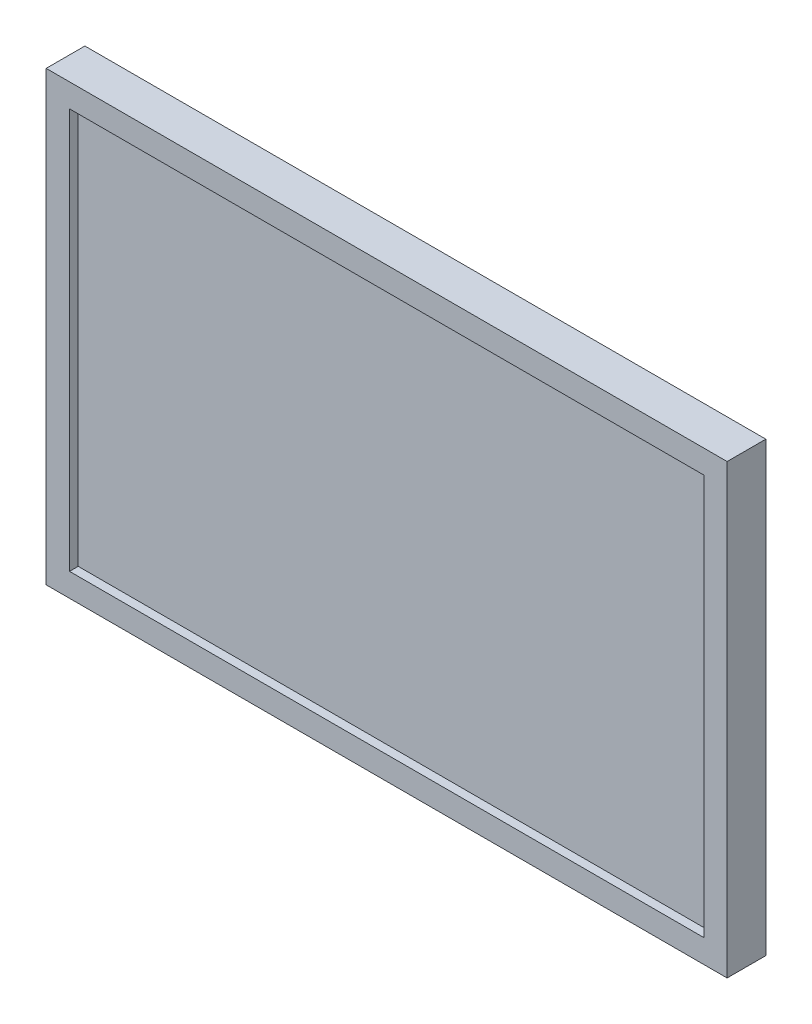
from build123d import *

# Parameters (mm, degrees)
SKETCH1_W           = 510
SKETCH1_H           = 335
BOSS_EXTRUDE1_DEPTH = 29
SKETCH2_W           = 475
SKETCH2_H           = 300
CUT_EXTRUDE1_DEPTH  = 6.5
SKETCH3_W           = 122
SKETCH3_H           = 122
BOSS_EXTRUDE2_DEPTH = 56
SKETCH4_R           = 2
CUT_EXTRUDE2_DEPTH  = 10
BOSS_EXTRUDE3_START = -56
SKETCH5_W           = 250
SKETCH5_H           = 154
SKETCH5_W_2         = 122
SKETCH5_H_2         = 122
BOSS_EXTRUDE3_DEPTH = 63
BOSS_EXTRUDE4_REACH = 360.798
BOSS_EXTRUDE5_REACH = 379.454
CUT_EXTRUDE3_DEPTH  = 63


with BuildPart() as part:
    # Sketch1 → Boss-Extrude1 (new body)
    with BuildSketch(Plane.XY):
        Rectangle(SKETCH1_W, SKETCH1_H)
    extrude(amount=-BOSS_EXTRUDE1_DEPTH)

    # Sketch2 → Cut-Extrude1 (cut)
    with BuildSketch(Plane.XY):
        Rectangle(SKETCH2_W, SKETCH2_H)
    extrude(amount=-CUT_EXTRUDE1_DEPTH, mode=Mode.SUBTRACT)

    # Sketch3 → Boss-Extrude2 (add)
    with BuildSketch(Plane(origin=(0, 0, -29), x_dir=(-1, 0, 0), z_dir=(0, 0, -1))):
        with Locations((0, 0.5)):
            Rectangle(SKETCH3_W, SKETCH3_H)
    extrude(amount=BOSS_EXTRUDE2_DEPTH)

    # Sketch4 → Cut-Extrude2 (cut)
    with BuildSketch(Plane(origin=(0, 0, -85), x_dir=(-1, 0, 0), z_dir=(0, 0, -1))):
        with Locations((-50, 50)):
            Circle(SKETCH4_R)
        with Locations((50, 50)):
            Circle(SKETCH4_R)
        with Locations((50, -50)):
            Circle(SKETCH4_R)
        with Locations((-50, -50)):
            Circle(SKETCH4_R)
    extrude(amount=-CUT_EXTRUDE2_DEPTH, mode=Mode.SUBTRACT)

    # Sketch5 → Boss-Extrude3 (add)
    with BuildSketch(Plane(origin=(0, 0, -85), x_dir=(-1, 0, 0), z_dir=(0, 0, -1)).offset(BOSS_EXTRUDE3_START)):
        with Locations((0, 3.5)):
            Rectangle(SKETCH5_W, SKETCH5_H)
        with Locations((0, 0.5)):
            Rectangle(SKETCH5_W_2, SKETCH5_H_2, mode=Mode.SUBTRACT)
    extrude(amount=BOSS_EXTRUDE3_DEPTH)

    # Sketch7 → Boss-Extrude4 (add, up to next)
    with BuildSketch(Plane(origin=(0, -65.329597813, -97.475907848), x_dir=(1, 0, 0), z_dir=(0, 0.55673786293741, 0.8306882399383573)), mode=Mode.PRIVATE) as boss_extrude4_sk1:
        Polygon((255, -122.994882164), (125, -9.835702245), (-125, -9.835702245), (-255, -122.994882164), align=None)
    boss_extrude4_tool1 = extrude(boss_extrude4_sk1.sketch, amount=BOSS_EXTRUDE4_REACH, mode=Mode.PRIVATE) - part.part
    add(boss_extrude4_tool1.solids().sort_by_distance((0, -125.859649, -56.907895))[0])

    # Sketch8 → Boss-Extrude5 (add, up to next)
    with BuildSketch(Plane(origin=(-59.87852796, 0, -123.558867219), x_dir=(0.8998964379962335, 0, -0.4361036584135601), z_dir=(0.4361036584135601, 0, 0.8998964379962335)), mode=Mode.PRIVATE) as boss_extrude5_sk1:
        Polygon((-216.826585595, 167.5), (-216.826585595, -167.5), (-72.365518175, -73.5), (-72.365518175, 80.5), align=None)
    boss_extrude5_tool1 = extrude(boss_extrude5_sk1.sketch, amount=BOSS_EXTRUDE5_REACH, mode=Mode.PRIVATE) - part.part
    boss_extrude5 = boss_extrude5_tool1.solids().sort_by_distance((-198.019768, 1.534083, -56.613497))[0]
    add(boss_extrude5)

    # Sketch9 → Cut-Extrude3 (cut)
    with BuildSketch(Plane(origin=(0, 0, -92), x_dir=(-1, 0, 0), z_dir=(0, 0, -1))):
        Polygon((0, 167.5), (255, 167.5), (125, 80.5), (0, 80.5), align=None)
    cut_extrude3 = extrude(amount=-CUT_EXTRUDE3_DEPTH, mode=Mode.SUBTRACT)

    # Mirror1: Boss-Extrude5, Cut-Extrude3 across plane
    add(boss_extrude5.mirror(Plane(origin=(0, 0, 0), x_dir=(0, 0, 1), z_dir=(1, 0, 0))))
    add(cut_extrude3.mirror(Plane(origin=(0, 0, 0), x_dir=(0, 0, 1), z_dir=(1, 0, 0))), mode=Mode.SUBTRACT)


solid = part.part
